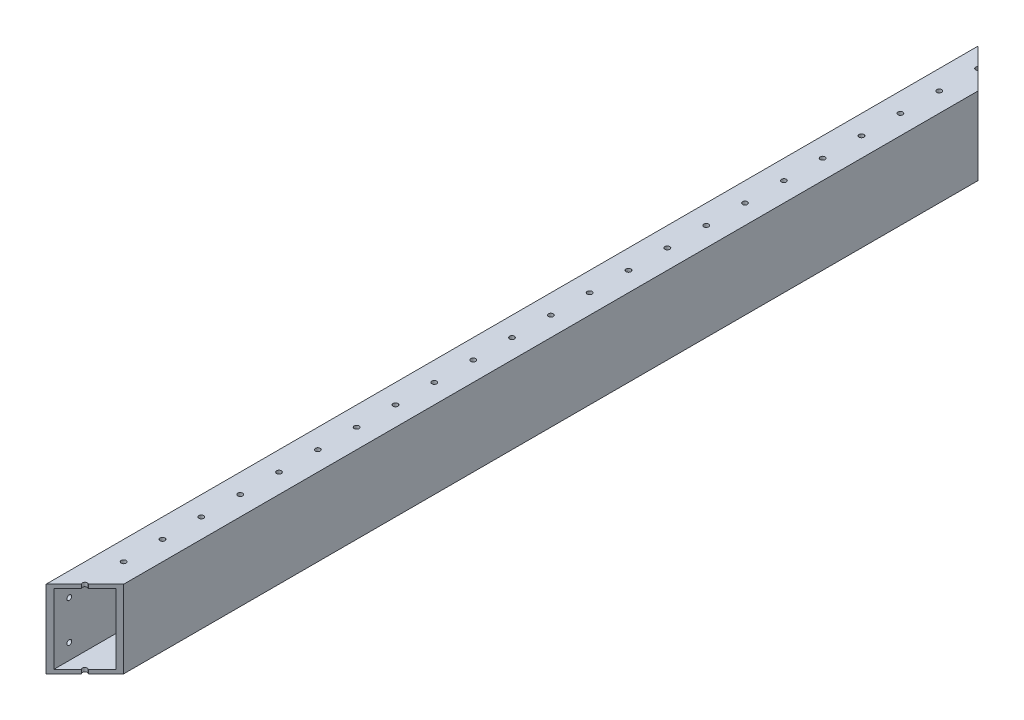
from build123d import *

# Parameters (mm, degrees)
SKETCH1_W           = 25.4
SKETCH1_H           = 50.8
SKETCH1_W_2         = 20.32
SKETCH1_H_2         = 45.72
EXTRUDE_THIN1_DEPTH = 609.6
SKETCH2_R           = 1.5875
CUT_EXTRUDE1_DEPTH  = 51.8
LPATTERN1_COUNT     = 50
LPATTERN1_PITCH     = 25.4
CUT_EXTRUDE2_DEPTH  = 51.8
SKETCH5_R           = 1.5875
CUT_EXTRUDE3_DEPTH  = 26.4


with BuildPart() as part:
    # Sketch1 → Extrude-Thin1 (new body)
    with BuildSketch(Plane.XY):
        with Locations((12.7, 25.4)):
            Rectangle(SKETCH1_W, SKETCH1_H)
        with Locations((12.7, 25.4)):
            Rectangle(SKETCH1_W_2, SKETCH1_H_2, mode=Mode.SUBTRACT)
    extrude(amount=EXTRUDE_THIN1_DEPTH)

    # Sketch2 → Cut-Extrude1 (cut, through all)
    with BuildSketch(Plane(origin=(0, 50.8, 0), x_dir=(1, 0, 0), z_dir=(0, 1, 0))):
        with Locations((12.7, -596.9)):
            Circle(SKETCH2_R)
    cut_extrude1 = extrude(amount=-CUT_EXTRUDE1_DEPTH, mode=Mode.SUBTRACT)

    # LPattern1: Cut-Extrude1 ×50
    with Locations(*[(0, 0, -i * LPATTERN1_PITCH) for i in range(1, LPATTERN1_COUNT)]):
        add(cut_extrude1, mode=Mode.SUBTRACT)

    # Sketch4 → Cut-Extrude2 (cut, through all)
    with BuildSketch(Plane(origin=(0, 50.8, 0), x_dir=(1, 0, 0), z_dir=(0, 1, 0))):
        Polygon((0, -609.6), (25.4, -584.2), (25.4, -609.6), align=None)
        Polygon((0, 0), (25.4, 0), (25.4, -25.4), align=None)
    extrude(amount=-CUT_EXTRUDE2_DEPTH, mode=Mode.SUBTRACT)

    # Sketch5 → Cut-Extrude3 (cut, through all)
    with BuildSketch(Plane.ZY):
        with Locations((12.7, 12.7)):
            Circle(SKETCH5_R)
        with Locations((12.7, 38.1)):
            Circle(SKETCH5_R)
        with Locations((596.9, 38.1)):
            Circle(SKETCH5_R)
        with Locations((596.9, 12.7)):
            Circle(SKETCH5_R)
    extrude(amount=-CUT_EXTRUDE3_DEPTH, mode=Mode.SUBTRACT)


solid = part.part
